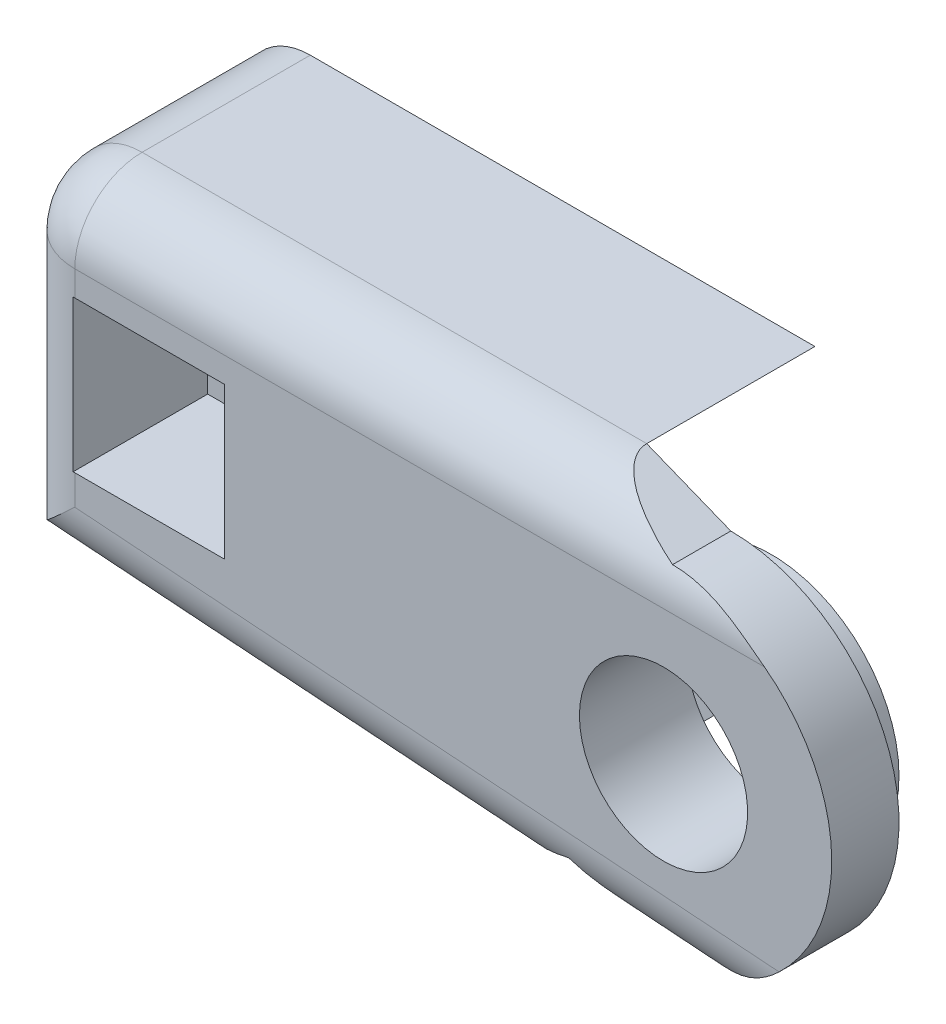
from build123d import *

# Parameters (mm, degrees)
BOSS_EXTRUDE1_DEPTH = 2
SKETCH3_R           = 2.5
CUT_EXTRUDE1_DEPTH  = 2
BOSS_EXTRUDE2_DEPTH = 5
FILLET2_R           = 2
SKETCH8_R           = 3.8
SKETCH8_R_2         = 2.5
BOSS_EXTRUDE3_DEPTH = 1.2
SKETCH7_R           = 0.5000000000000009
CUT_EXTRUDE3_DEPTH  = 2
SKETCH15_R          = 0.5000000000000009
CUT_EXTRUDE5_DEPTH  = 3
SKETCH18_W          = 7
SKETCH18_H          = 7.573769237451616
BOSS_EXTRUDE4_DEPTH = 5
SKETCH19_R          = 0.9999999999999996
CUT_EXTRUDE6_DEPTH  = 3
SKETCH20_W          = 4.499999999999998
SKETCH20_H          = 4.5
CUT_EXTRUDE7_DEPTH  = 5


with BuildPart() as part:
    # Sketch2 → Boss-Extrude1 (new body)
    with BuildSketch(Plane.XY):
        with BuildLine():
            Line((0, 5.000000000000001), (-2.5, 6))
            Line((-2.5, 6), (-19.499999999999996, 5.999999999999998))
            Line((-19.499999999999996, 5.999999999999998), (-19.499999999999996, -4.000000000000002))
            Line((-19.499999999999996, -4.000000000000002), (-5.4999999999999964, -4.999999999999999))
            Line((-5.4999999999999964, -4.999999999999999), (-2.999999999999996, -4.0000000000000036))
            ThreePointArc((-2.999999999999996, -4.0000000000000036), (4.743416490252571, -1.5811388300841875), (0, 5.000000000000001))
        make_face()
    extrude(amount=BOSS_EXTRUDE1_DEPTH)

    # Sketch3 → Cut-Extrude1 (cut)
    with BuildSketch(Plane(origin=(0, 0, 0), x_dir=(-1, 0, 0), z_dir=(0, 0, -1))):
        Circle(SKETCH3_R)
    extrude(amount=-CUT_EXTRUDE1_DEPTH, mode=Mode.SUBTRACT)

    # Sketch4 → Boss-Extrude2 (add)
    with BuildSketch(Plane.XY.offset(2)):
        Polygon((-19.499999999999996, -4.000000000000002), (-19.499999999999996, 5.999999999999998), (-2.5, 6), (-5.349362666614333, 4.499999999999999), (-18.299999999999997, 4.499999999999997), (-18.299999999999997, -2.581892623469482), (-6.7590791740868275, -3.4062441110347046), (-5.4999999999999964, -4.999999999999999), (-19.292624540521615, -4.014812532819887), align=None)
    extrude(amount=BOSS_EXTRUDE2_DEPTH)

    # Fillet2
    fillet2_edges = [part.edges().sort_by_distance(p)[0] for p in [
        (-19.499999999999996, 0.9999999999999982, 0),
        (-19.499999999999996, 5.999999999999998, 3.5),
        (-12.499999999999996, -4.5, 0),
        (-10.999999999999998, 5.999999999999999, 0),
    ]]
    fillet(fillet2_edges, radius=FILLET2_R)

    # Sketch8 → Boss-Extrude3 (add)
    with BuildSketch(Plane.XY.offset(2)):
        Circle(SKETCH8_R)
        with Locations(Location((0, 0, 0), (0, 0, 180))):
            Circle(SKETCH8_R_2, mode=Mode.SUBTRACT)
    extrude(amount=BOSS_EXTRUDE3_DEPTH)

    # Sketch7 → Cut-Extrude3 (cut, along a direction that is not the sketch's normal)
    with BuildSketch(Plane.XZ.offset(-4.5)):
        with Locations((-10.349362666614333, 7)):
            Circle(SKETCH7_R)
    extrude(amount=-CUT_EXTRUDE3_DEPTH, dir=(0.6843021216730707, -0.7291986055072609, 0), mode=Mode.SUBTRACT)

    # Sketch15 → Cut-Extrude5 (cut, along a direction that is not the sketch's normal)
    with BuildSketch(Plane(origin=(-0.2763781559826011, -3.869294183756433, 0), x_dir=(0.9974586998307351, -0.07124704998790933, 0), z_dir=(0.07124704998790933, 0.9974586998307351, 0))):
        with Locations((-9.537755541479953, -7)):
            Circle(SKETCH15_R)
    extrude(amount=-CUT_EXTRUDE5_DEPTH, dir=(0.7271985173785733, 0.6864272112339407, 0), mode=Mode.SUBTRACT)

    # Sketch18 → Boss-Extrude4 (add)
    with BuildSketch(Plane.XY.offset(2)):
        with Locations((-14.799999999999997, 0.7131153812741895)):
            Rectangle(SKETCH18_W, SKETCH18_H)
    extrude(amount=BOSS_EXTRUDE4_DEPTH)

    # Sketch19 → Cut-Extrude6 (cut)
    with BuildSketch(Plane.XY.offset(6.999999999999999)):
        with Locations((-15.299999999999997, 0.9999999999999972)):
            Circle(SKETCH19_R)
    extrude(amount=-CUT_EXTRUDE6_DEPTH, mode=Mode.SUBTRACT)

    # Sketch20 → Cut-Extrude7 (cut)
    with BuildSketch(Plane.XY.offset(3.999999999999999)):
        with Locations((-15.299999999999997, 0.9999999999999969)):
            Rectangle(SKETCH20_W, SKETCH20_H)
    extrude(amount=-CUT_EXTRUDE7_DEPTH, mode=Mode.SUBTRACT)

    # Mirror1: part across plane


with BuildPart() as part_1:
    add(part.part)
    add(part.part.mirror(Plane.XY.offset(6.999999999999999)))


with BuildPart() as body_2:
    # Split1: the piece on the far side of the plane
    add(part_1.part)
    split(bisect_by=Plane.XY.offset(6.999999999999999), keep=Keep.BOTTOM)


with BuildPart() as part_2:
    add(part_1.part)

    # Split1
    split(bisect_by=Plane.XY.offset(6.999999999999999), keep=Keep.TOP)


solid = part_2.part
